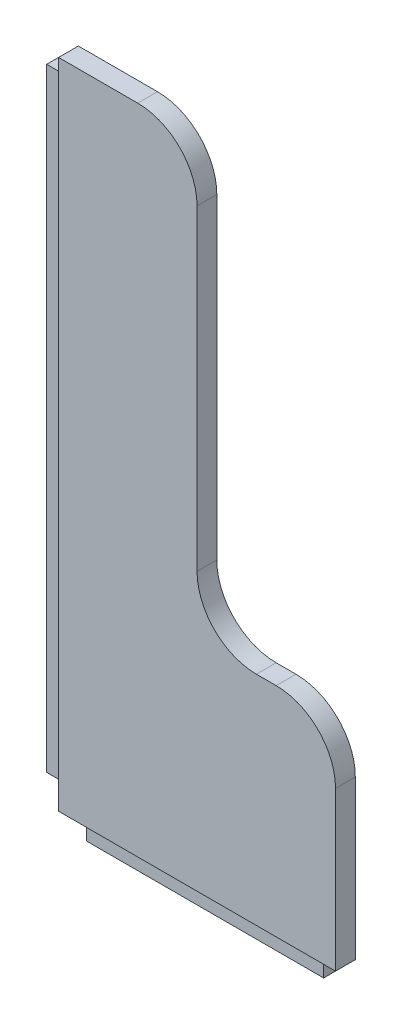
from build123d import *

# Parameters (mm, degrees)
SALIENTE_EXTRUIR3_DEPTH = 6.35
CROQUIS5_W              = 2.54
CROQUIS5_H              = 196.85
CORTAR_EXTRUIR1_DEPTH   = 6.35
CROQUIS6_W              = 6.35
CROQUIS6_H              = 196.85
CROQUIS6_W_2            = 76.2
CROQUIS6_H_2            = 6.35
CORTAR_EXTRUIR2_DEPTH   = 7.35
CROQUIS7_W              = 3.81
CROQUIS7_H              = 196.85
SALIENTE_EXTRUIR5_DEPTH = 6.35
CROQUIS8_W              = 76.2
CROQUIS8_H              = 3.81
SALIENTE_EXTRUIR6_DEPTH = 6.35


with BuildPart() as part:
    # Croquis2 → Saliente-Extruir3 (new body)
    with BuildSketch(Plane.XY):
        with BuildLine():
            Line((0, 0), (6.35, 0))
            Line((6.35, 0), (6.35, -6.35))
            Line((6.35, -6.35), (82.55, -6.35))
            Line((82.55, -6.35), (82.55, 0))
            Line((82.55, 0), (88.9, 0))
            Line((88.9, 0), (88.9, 50.8))
            ThreePointArc((88.9, 50.8), (83.320384182, 64.270384182), (69.85, 69.85))
            Line((69.85, 69.85), (63.5, 69.85))
            ThreePointArc((63.5, 69.85), (50.029615818, 75.429615818), (44.45, 88.9))
            Line((44.45, 88.9), (44.45, 190.5))
            ThreePointArc((44.45, 190.5), (38.870384182, 203.970384182), (25.4, 209.55))
            Line((25.4, 209.55), (0, 209.55))
            Line((0, 209.55), (0, 203.2))
            Line((0, 203.2), (-6.35, 203.2))
            Line((-6.35, 203.2), (-6.35, 6.35))
            Line((-6.35, 6.35), (0, 6.35))
            Line((0, 6.35), (0, 0))
        make_face()
    extrude(amount=SALIENTE_EXTRUIR3_DEPTH)

    # Croquis5 → Cortar-Extruir1 (cut)
    with BuildSketch(Plane.ZY.offset(6.35)):
        with Locations((1.27, 104.775)):
            Rectangle(CROQUIS5_W, CROQUIS5_H)
    extrude(amount=-CORTAR_EXTRUIR1_DEPTH, mode=Mode.SUBTRACT)


with BuildPart() as part_1:
    # Sólido-Mover/Copiar1: moved
    add(part.part.moved(Location((-148.301048564, -44.960118156, 222.608991853))))

    # Croquis6 → Cortar-Extruir2 (cut, through all)
    with BuildSketch(Plane.XY.offset(228.958991853)):
        with Locations((-151.476048564, 59.814881844)):
            Rectangle(CROQUIS6_W, CROQUIS6_H)
        with Locations((-103.851048564, -48.135118156)):
            Rectangle(CROQUIS6_W_2, CROQUIS6_H_2)
    extrude(amount=-CORTAR_EXTRUIR2_DEPTH, mode=Mode.SUBTRACT)

    # Croquis7 → Saliente-Extruir5 (add)
    with BuildSketch(Plane.ZY.offset(148.301048564)):
        with Locations((224.513991853, 59.814881844)):
            Rectangle(CROQUIS7_W, CROQUIS7_H)
    extrude(amount=SALIENTE_EXTRUIR5_DEPTH)

    # Croquis8 → Saliente-Extruir6 (add)
    with BuildSketch(Plane(origin=(0, -44.960118156, 0), x_dir=(-1, 0, 0), z_dir=(0, -1, 0))):
        with Locations((103.851048564, -224.513991853)):
            Rectangle(CROQUIS8_W, CROQUIS8_H)
    extrude(amount=SALIENTE_EXTRUIR6_DEPTH)


solid = part_1.part
